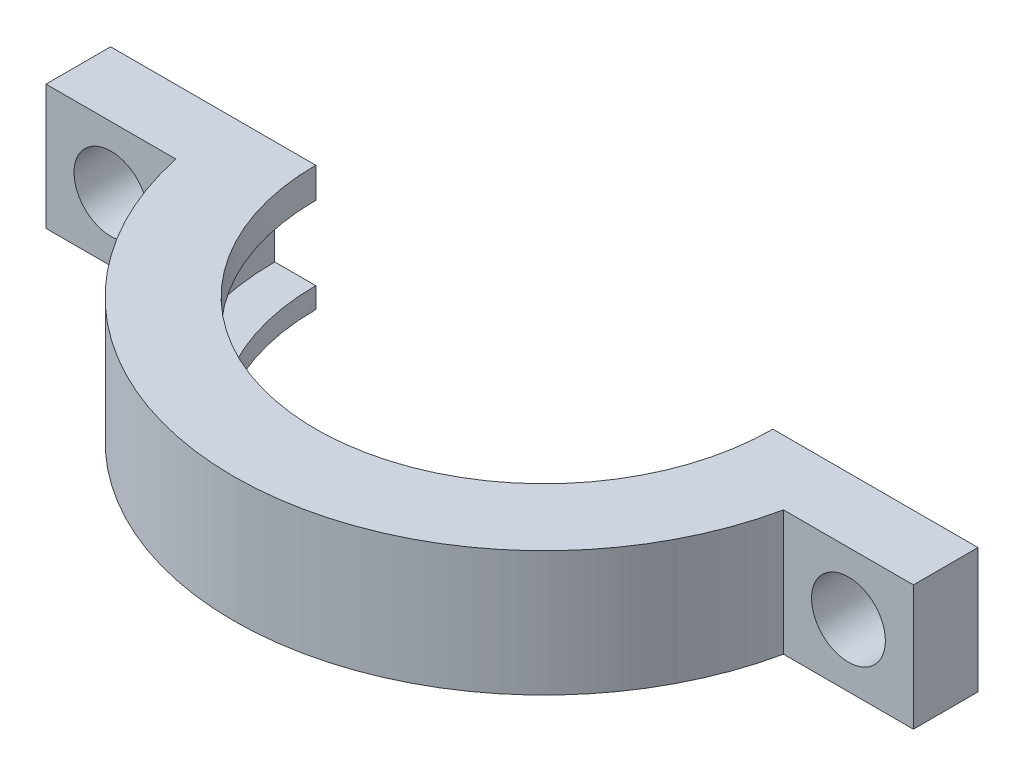
from build123d import *

# Parameters (mm, degrees)
BOSS_EXTRUDE1_DEPTH     = 5
BOSS_EXTRUDE2_DEPTH     = 3
BOSS_EXTRUDE3_DEPTH     = 3
SKETCH10_W              = 9.5
SKETCH10_H              = 5
BOSS_EXTRUDE4_DEPTH     = 15.78
SKETCH11_W              = 9.5
SKETCH11_H              = 2
BOSS_EXTRUDE5_DEPTH     = 40
BOSS_EXTRUDE6_DEPTH     = 6.09393
SKETCH14_R              = 1.8
CUT_EXTRUDE1_DEPTH      = 6.3
SKETCH15_W              = 51.153217575
SKETCH15_H              = 86.05062267
CUT_EXTRUDE3_DEPTH      = 6
CUT_EXTRUDE3_DEPTH_BACK = 19.78
SKETCH16_W              = 9.603970124
SKETCH16_H              = 11.884913028
CUT_EXTRUDE4_DEPTH      = 17.733728816


with BuildPart() as part:
    # Sketch3 → Revolve1 (revolve)
    with BuildSketch(Plane.XY):
        Polygon((-62.694264441, 11.733728816), (-64.884531744, 11.733728816), (-64.884531744, 5.639799249), (-60.884531744, 5.639799249), (-60.884531744, 6.650679103), (-62.884531744, 6.650679103), (-62.884531744, 10.250679103), (-60.884531744, 10.250679103), (-60.884531744, 11.733728816), align=None)
    revolve(axis=Axis((-49.744264441, 0, 0), (0, 1, 0)))

    # Sketch7 → Boss-Extrude1 (add)
    with BuildSketch(Plane(origin=(0, 11.733728816, 0), x_dir=(1, 0, 0), z_dir=(0, 1, 0))):
        with BuildLine():
            Line((-50.244264441, 15.132008921), (-50.244264441, 13.130751112))
            ThreePointArc((-50.244264441, 13.130751112), (-49.744264441, 13.140267302), (-49.244264441, 13.130751112))
            Line((-49.244264441, 13.130751112), (-49.244264441, 15.132008921))
            ThreePointArc((-49.244264441, 15.132008921), (-49.744264441, 15.140267302), (-50.244264441, 15.132008921))
        make_face()
    extrude(amount=BOSS_EXTRUDE1_DEPTH)

    # Sketch8 → Boss-Extrude2 (add)
    with BuildSketch(Plane(origin=(0, 16.733728816, 0), x_dir=(1, 0, 0), z_dir=(0, 1, 0))):
        with BuildLine():
            Line((-50.244264441, 15.132008921), (-50.244264441, 13.130751112))
            Line((-50.244264441, 13.130751112), (-50.244264441, -4.369248888))
            Line((-50.244264441, -4.369248888), (-49.244264441, -4.369248888))
            Line((-49.244264441, -4.369248888), (-49.244264441, 13.130751112))
            Line((-49.244264441, 13.130751112), (-49.244264441, 15.132008921))
            ThreePointArc((-49.244264441, 15.132008921), (-49.744264441, 15.140267302), (-50.244264441, 15.132008921))
        make_face()
    extrude(amount=-BOSS_EXTRUDE2_DEPTH)

    # Sketch9 → Boss-Extrude3 (add)
    with BuildSketch(Plane(origin=(0, 11.733728816, 0), x_dir=(1, 0, 0), z_dir=(0, 1, 0))):
        with BuildLine():
            Line((-54.494264441, 14.375854548), (-54.494264441, 39.375854548))
            Line((-54.494264441, 39.375854548), (-44.994264441, 39.375854548))
            Line((-44.994264441, 39.375854548), (-44.994264441, 14.375854548))
            ThreePointArc((-44.994264441, 14.375854548), (-47.092177082, 14.906177465), (-49.244264441, 15.132008921))
            ThreePointArc((-49.244264441, 15.132008921), (-49.744264441, 15.140267302), (-50.244264441, 15.132008921))
            ThreePointArc((-50.244264441, 15.132008921), (-52.3963518, 14.906177465), (-54.494264441, 14.375854548))
        make_face()
    extrude(amount=-BOSS_EXTRUDE3_DEPTH)

    # Sketch10 → Boss-Extrude4 (add)
    with BuildSketch(Plane.XZ.offset(-8.733728816)):
        with Locations((-49.744264441, -36.875854548)):
            Rectangle(SKETCH10_W, SKETCH10_H)
    extrude(amount=BOSS_EXTRUDE4_DEPTH)

    # Sketch11 → Boss-Extrude5 (add)
    with BuildSketch(Plane(origin=(0, 0, -39.375854548), x_dir=(-1, 0, 0), z_dir=(0, 0, -1))):
        with Locations((49.744264441, -6.046271184)):
            Rectangle(SKETCH11_W, SKETCH11_H)
    extrude(amount=BOSS_EXTRUDE5_DEPTH)

    # Sketch13 → Boss-Extrude6 (add)
    with BuildSketch(Plane(origin=(0, 11.733728816, 0), x_dir=(1, 0, 0), z_dir=(0, 1, 0))):
        with BuildLine():
            Line((-28.603997139, 3.15), (-34.935307895, 3.15))
            ThreePointArc((-34.935307895, 3.15), (-34.603997139, 0), (-34.935307895, -3.15))
            Line((-34.935307895, -3.15), (-28.603997139, -3.15))
            Line((-28.603997139, -3.15), (-28.603997139, 3.15))
        make_face()
        with BuildLine():
            Line((-70.884531744, 3.15), (-70.884531744, -3.15))
            Line((-70.884531744, -3.15), (-64.553220987, -3.15))
            ThreePointArc((-64.553220987, -3.15), (-64.884531744, 0), (-64.553220987, 3.15))
            Line((-64.553220987, 3.15), (-70.884531744, 3.15))
        make_face()
    extrude(amount=-BOSS_EXTRUDE6_DEPTH)

    # Sketch14 → Cut-Extrude1 (cut)
    with BuildSketch(Plane.XY.offset(3.15)):
        with Locations((-31.769652517, 8.686764033)):
            Circle(SKETCH14_R)
        with Locations((-67.718876365, 8.686764033)):
            Circle(SKETCH14_R)
    extrude(amount=-CUT_EXTRUDE1_DEPTH, mode=Mode.SUBTRACT)

    # Sketch15 → Cut-Extrude3 (cut, two sides)
    with BuildSketch(Plane(origin=(0, 11.733728816, 0), x_dir=(1, 0, 0), z_dir=(0, 1, 0))) as cut_extrude3_sk:
        with Locations((-49.018725857, 43.025311335)):
            Rectangle(SKETCH15_W, SKETCH15_H)
    extrude(amount=CUT_EXTRUDE3_DEPTH, mode=Mode.SUBTRACT)
    extrude(cut_extrude3_sk.sketch, amount=-CUT_EXTRUDE3_DEPTH_BACK, mode=Mode.SUBTRACT)

    # Sketch16 → Cut-Extrude4 (cut, through all)
    with BuildSketch(Plane(origin=(0, 0, 0), x_dir=(1, 0, 0), z_dir=(0, 1, 0))):
        with Locations((-50.086315959, -0.525030424)):
            Rectangle(SKETCH16_W, SKETCH16_H)
    extrude(amount=CUT_EXTRUDE4_DEPTH, mode=Mode.SUBTRACT)


solid = part.part
